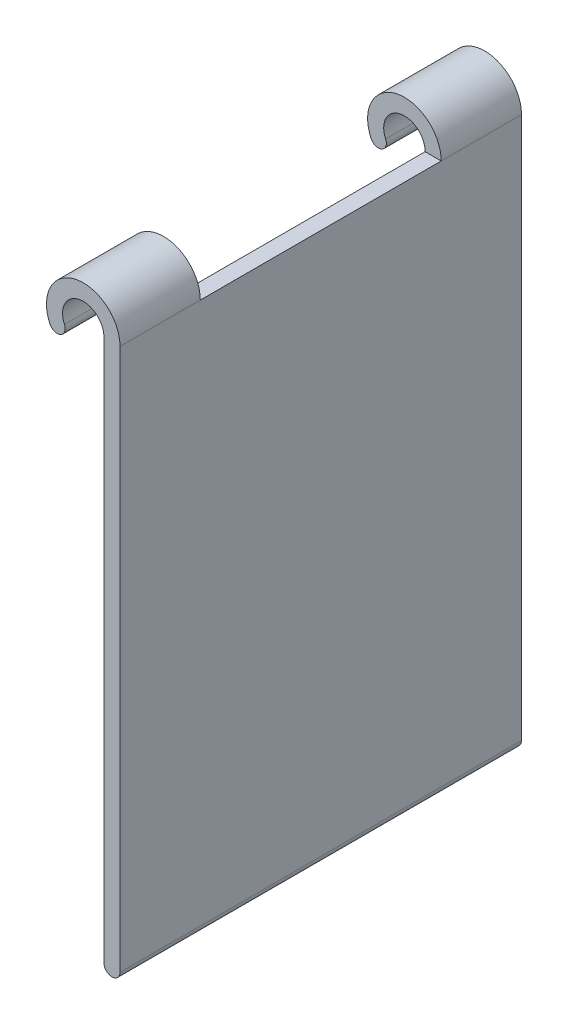
from build123d import *

# Parameters (mm, degrees)
BOSS_EXTRUDE1_DEPTH = 6.35
BOSS_EXTRUDE2_START = 50.8
BOSS_EXTRUDE2_DEPTH = 50.8
LPATTERN1_COUNT     = 2
LPATTERN1_PITCH     = 50.8
BOSS_EXTRUDE3_DEPTH = 6.35


with BuildPart() as part:
    # Sketch1 → Boss-Extrude1 (new, symmetric)
    with BuildSketch(Plane.XY):
        with BuildLine():
            Line((3.2766, 0), (3.2766, -85.725))
            ThreePointArc((3.2766, -85.725), (4.5466, -86.995), (5.8166, -85.725))
            Line((5.8166, -85.725), (5.8166, 0))
            ThreePointArc((5.8166, 0), (-1.258942658, 5.678723355), (-5.271629874, -2.458201381))
            ThreePointArc((-5.271629874, -2.458201381), (-3.583893792, -3.072487078), (-2.969608095, -1.384750996))
            ThreePointArc((-2.969608095, -1.384750996), (-0.709186039, 3.198931497), (3.2766, 0))
        make_face()
    boss_extrude1 = extrude(amount=BOSS_EXTRUDE1_DEPTH, both=True)

    # Sketch2 → Boss-Extrude2 (add)
    with BuildSketch(Plane.XY.offset(6.35).offset(BOSS_EXTRUDE2_START)):
        with BuildLine():
            Line((3.2766, 0), (5.8166, 0))
            Line((5.8166, 0), (5.8166, -85.725))
            ThreePointArc((5.8166, -85.725), (4.5466, -86.995), (3.2766, -85.725))
            Line((3.2766, -85.725), (3.2766, 0))
        make_face()
    extrude(amount=-BOSS_EXTRUDE2_DEPTH)

    # LPattern1: Boss-Extrude1 ×2
    with Locations(*[(0, 0, i * LPATTERN1_PITCH) for i in range(1, LPATTERN1_COUNT)]):
        add(boss_extrude1)

    # Sketch4 → Boss-Extrude3 (add, symmetric)
    with BuildSketch(Plane.XY.offset(25.4)):
        with BuildLine():
            Line((3.2766, -66.802), (3.2766, -71.607905534))
            ThreePointArc((3.2766, -71.607905534), (-3.956296051, -71.065866451), (-5.037323364, -63.8937))
            Line((-5.037323364, -63.8937), (-2.837618838, -65.1637))
            ThreePointArc((-2.837618838, -65.1637), (-0.848046483, -69.966952562), (3.2766, -66.802))
        make_face()
    extrude(amount=BOSS_EXTRUDE3_DEPTH, both=True)


solid = part.part
